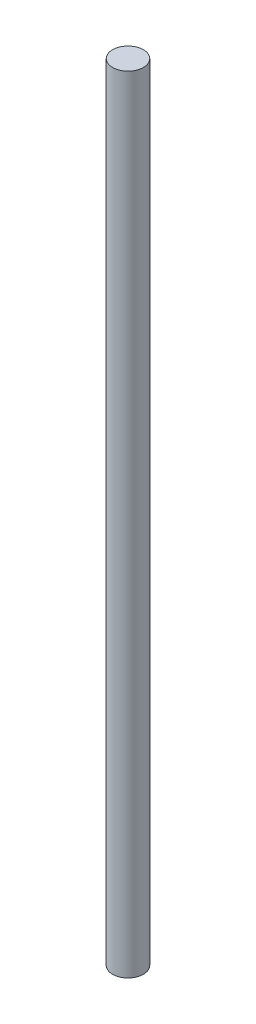
from build123d import *

# Parameters (mm, degrees)
SKETCH1_R           = 3
BOSS_EXTRUDE1_DEPTH = 153


with BuildPart() as part:
    # Sketch1 → Boss-Extrude1 (new body)
    with BuildSketch(Plane(origin=(0, 0, 0), x_dir=(1, 0, 0), z_dir=(0, 1, 0))):
        Circle(SKETCH1_R)
    extrude(amount=BOSS_EXTRUDE1_DEPTH)


solid = part.part
